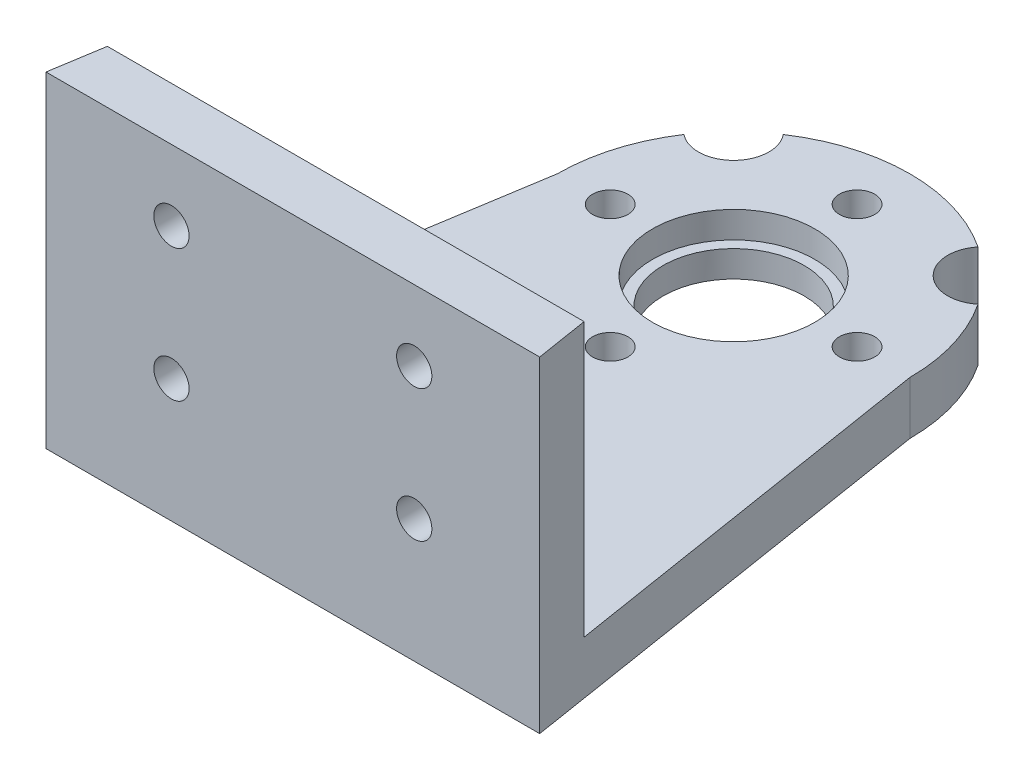
from build123d import *

# Parameters (mm, degrees)
BOSS_EXTRUDE1_DEPTH = 3
SKETCH2_R           = 4
CUT_EXTRUDE1_DEPTH  = 13
SKETCH3_R           = 1
CUT_EXTRUDE2_DEPTH  = 13
SKETCH4_R           = 1
CUT_EXTRUDE3_DEPTH  = 3
BOSS_EXTRUDE2_DEPTH = 15.5
SKETCH6_R           = 4.6
CUT_EXTRUDE4_DEPTH  = 1.5
SKETCH7_R           = 2
CUT_EXTRUDE5_DEPTH  = 10
SKETCH8_R           = 1
CUT_EXTRUDE6_DEPTH  = 10


with BuildPart() as part:
    # Sketch1 → Boss-Extrude1 (new body)
    with BuildSketch(Plane(origin=(0, 0, 0), x_dir=(1, 0, 0), z_dir=(0, 1, 0))):
        with BuildLine():
            Line((-10, 0), (-14, -25))
            Line((-14, -25), (14, -25))
            Line((14, -25), (10, 0))
            ThreePointArc((10, 0), (0, 10), (-10, 0))
        make_face()
    extrude(amount=BOSS_EXTRUDE1_DEPTH)

    # Sketch2 → Cut-Extrude1 (cut)
    with BuildSketch(Plane(origin=(0, 3, 0), x_dir=(1, 0, 0), z_dir=(0, 1, 0))):
        Circle(SKETCH2_R)
    extrude(amount=-CUT_EXTRUDE1_DEPTH, mode=Mode.SUBTRACT)

    # Sketch3 → Cut-Extrude2 (cut)
    with BuildSketch(Plane(origin=(0, 3, 0), x_dir=(1, 0, 0), z_dir=(0, 1, 0))):
        with Locations((-6.52, -19)):
            Circle(SKETCH3_R)
        with Locations((6.52, -19)):
            Circle(SKETCH3_R)
        with Locations((0, -19)):
            Circle(SKETCH3_R)
    extrude(amount=-CUT_EXTRUDE2_DEPTH, mode=Mode.SUBTRACT)

    # Sketch4 → Cut-Extrude3 (cut)
    with BuildSketch(Plane(origin=(0, 3, 0), x_dir=(1, 0, 0), z_dir=(0, 1, 0))):
        with Locations((0, -7)):
            Circle(SKETCH4_R)
        with Locations((-7, 0)):
            Circle(SKETCH4_R)
        with Locations((0, 7)):
            Circle(SKETCH4_R)
        with Locations((7, 0)):
            Circle(SKETCH4_R)
    extrude(amount=-CUT_EXTRUDE3_DEPTH, mode=Mode.SUBTRACT)

    # Sketch5 → Boss-Extrude2 (add)
    with BuildSketch(Plane(origin=(0, 3, 0), x_dir=(1, 0, 0), z_dir=(0, 1, 0))):
        Polygon((-13.52, -22), (13.52, -22), (14, -25), (-14, -25), align=None)
    extrude(amount=BOSS_EXTRUDE2_DEPTH)

    # Sketch6 → Cut-Extrude4 (cut)
    with BuildSketch(Plane(origin=(0, 3, 0), x_dir=(1, 0, 0), z_dir=(0, 1, 0))):
        Circle(SKETCH6_R)
    extrude(amount=-CUT_EXTRUDE4_DEPTH, mode=Mode.SUBTRACT)

    # Sketch7 → Cut-Extrude5 (cut)
    with BuildSketch(Plane(origin=(0, 3, 0), x_dir=(1, 0, 0), z_dir=(0, 1, 0))):
        with Locations((-7.071067812, 7.071067812)):
            Circle(SKETCH7_R)
        with Locations((7.071067812, 7.071067812)):
            Circle(SKETCH7_R)
    extrude(amount=-CUT_EXTRUDE5_DEPTH, mode=Mode.SUBTRACT)

    # Sketch8 → Cut-Extrude6 (cut)
    with BuildSketch(Plane(origin=(0, 0, 22), x_dir=(-1, 0, 0), z_dir=(0, 0, -1))):
        with Locations((6.885, 14.5)):
            Circle(SKETCH8_R)
        with Locations((-6.885, 14.5)):
            Circle(SKETCH8_R)
        with Locations((6.885, 7)):
            Circle(SKETCH8_R)
        with Locations((-6.885, 7)):
            Circle(SKETCH8_R)
    extrude(amount=-CUT_EXTRUDE6_DEPTH, mode=Mode.SUBTRACT)


solid = part.part
